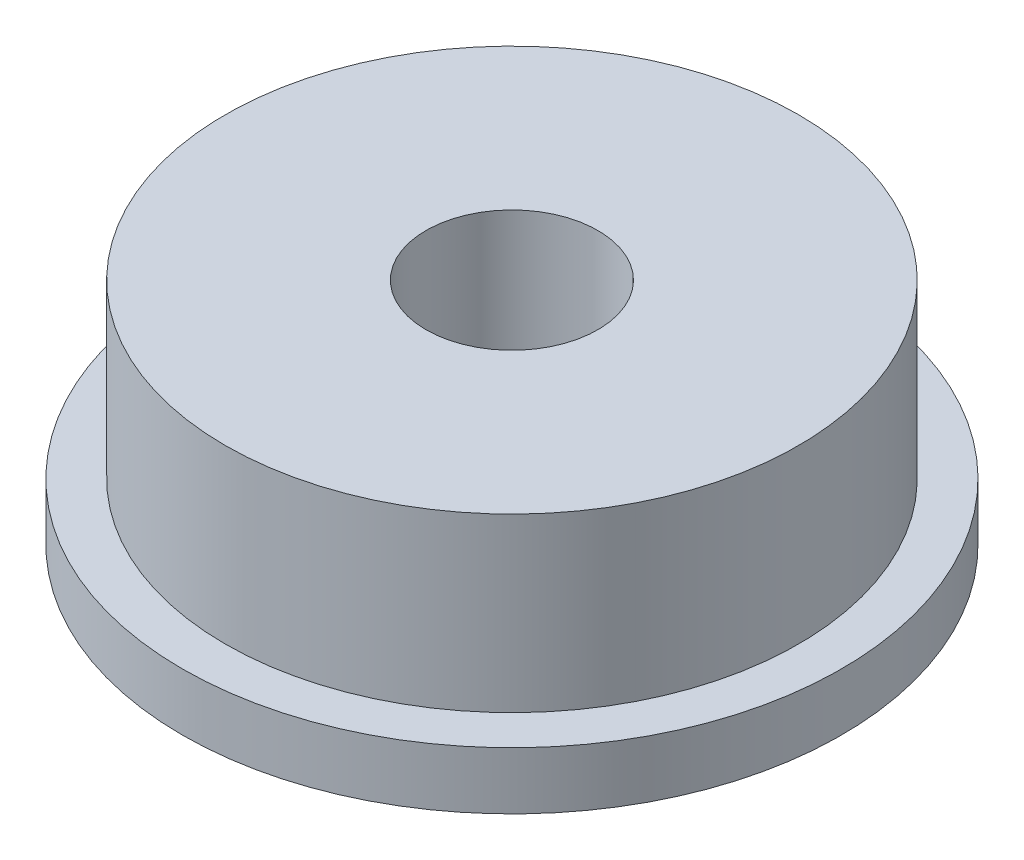
from build123d import *

# Parameters (mm, degrees)
SKETCH1_R           = 5
SKETCH1_R_2         = 1.5
BOSS_EXTRUDE1_DEPTH = 4
SKETCH1_3_R         = 5.75
SKETCH1_3_R_2       = 5
BOSS_EXTRUDE2_DEPTH = 1


with BuildPart() as part:
    # Sketch1 → Boss-Extrude1 (new body)
    with BuildSketch(Plane(origin=(0, 0, 0), x_dir=(1, 0, 0), z_dir=(0, 1, 0))):
        Circle(SKETCH1_R)
        Circle(SKETCH1_R_2, mode=Mode.SUBTRACT)
    extrude(amount=BOSS_EXTRUDE1_DEPTH)

    # Sketch1_3 → Boss-Extrude2 (add)
    with BuildSketch(Plane(origin=(0, 0, 0), x_dir=(1, 0, 0), z_dir=(0, 1, 0))):
        Circle(SKETCH1_3_R)
        Circle(SKETCH1_3_R_2, mode=Mode.SUBTRACT)
    extrude(amount=BOSS_EXTRUDE2_DEPTH)


solid = part.part
